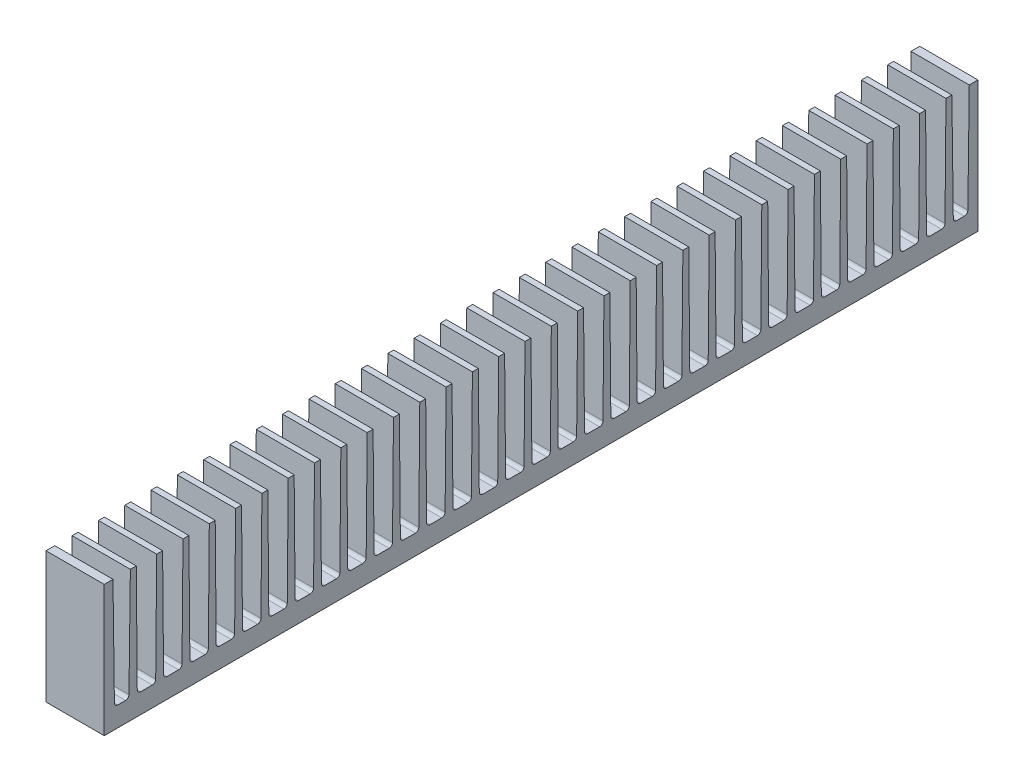
from build123d import *

# Parameters (mm, degrees)
SKETCH1_W           = 90
SKETCH1_H           = 13.5
BOSS_EXTRUDE1_DEPTH = 3
CUT_EXTRUDE1_DEPTH  = 6
CUT_EXTRUDE2_DEPTH  = 6
LPATTERN1_COUNT     = 31
LPATTERN1_PITCH     = 2.71


with BuildPart() as part:
    # Sketch1 → Boss-Extrude1 (new body, symmetric)
    with BuildSketch(Plane(origin=(0, 0, 0), x_dir=(0, 0, -1), z_dir=(1, 0, 0))):
        Rectangle(SKETCH1_W, SKETCH1_H)
    extrude(amount=BOSS_EXTRUDE1_DEPTH, both=True)

    # Sketch2 → Cut-Extrude1 (cut)
    with BuildSketch(Plane(origin=(3, 0, 0), x_dir=(0, 0, -1), z_dir=(1, 0, 0))):
        with BuildLine():
            Line((-44.1, 6.75), (-43.955, -4.354569801))
            ThreePointArc((-43.955, -4.354569801), (-43.850896231, -4.599097802), (-43.605029834, -4.7))
            Line((-43.605029834, -4.7), (-42.804970166, -4.7))
            ThreePointArc((-42.804970166, -4.7), (-42.559103769, -4.599097802), (-42.455, -4.354569801))
            Line((-42.455, -4.354569801), (-42.31, 6.75))
            Line((-42.31, 6.75), (-44.1, 6.75))
        make_face()
    cut_extrude1 = extrude(amount=-CUT_EXTRUDE1_DEPTH, mode=Mode.SUBTRACT)

    # Sketch3 → Cut-Extrude2 (cut)
    with BuildSketch(Plane(origin=(3, 0, 0), x_dir=(0, 0, -1), z_dir=(1, 0, 0))):
        with BuildLine():
            Line((-41.7, 6.75), (-39.6, 6.75))
            Line((-39.6, 6.75), (-39.7, -4.35315213))
            ThreePointArc((-39.7, -4.35315213), (-39.803615399, -4.598599322), (-40.049985806, -4.7))
            Line((-40.049985806, -4.7), (-41.250014194, -4.7))
            ThreePointArc((-41.250014194, -4.7), (-41.496384601, -4.598599322), (-41.6, -4.35315213))
            Line((-41.6, -4.35315213), (-41.7, 6.75))
        make_face()
    cut_extrude2 = extrude(amount=-CUT_EXTRUDE2_DEPTH, mode=Mode.SUBTRACT)

    # Mirror1: Cut-Extrude1 across plane
    add(cut_extrude1.mirror(Plane.XY), mode=Mode.SUBTRACT)

    # LPattern1: Cut-Extrude2 ×31
    with Locations(*[(0, 0, -i * LPATTERN1_PITCH) for i in range(1, LPATTERN1_COUNT)]):
        add(cut_extrude2, mode=Mode.SUBTRACT)


solid = part.part
